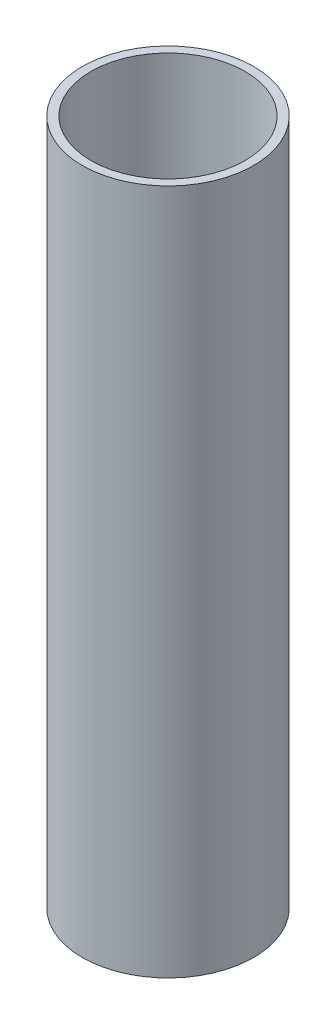
from build123d import *

# Parameters (mm, degrees)
SKETCH1_R           = 25
SKETCH1_R_2         = 22.5
BOSS_EXTRUDE1_DEPTH = 200


with BuildPart() as part:
    # Sketch1 → Boss-Extrude1 (new body)
    with BuildSketch(Plane(origin=(0, 0, 0), x_dir=(1, 0, 0), z_dir=(0, 1, 0))):
        Circle(SKETCH1_R)
        Circle(SKETCH1_R_2, mode=Mode.SUBTRACT)
    extrude(amount=BOSS_EXTRUDE1_DEPTH)


solid = part.part
